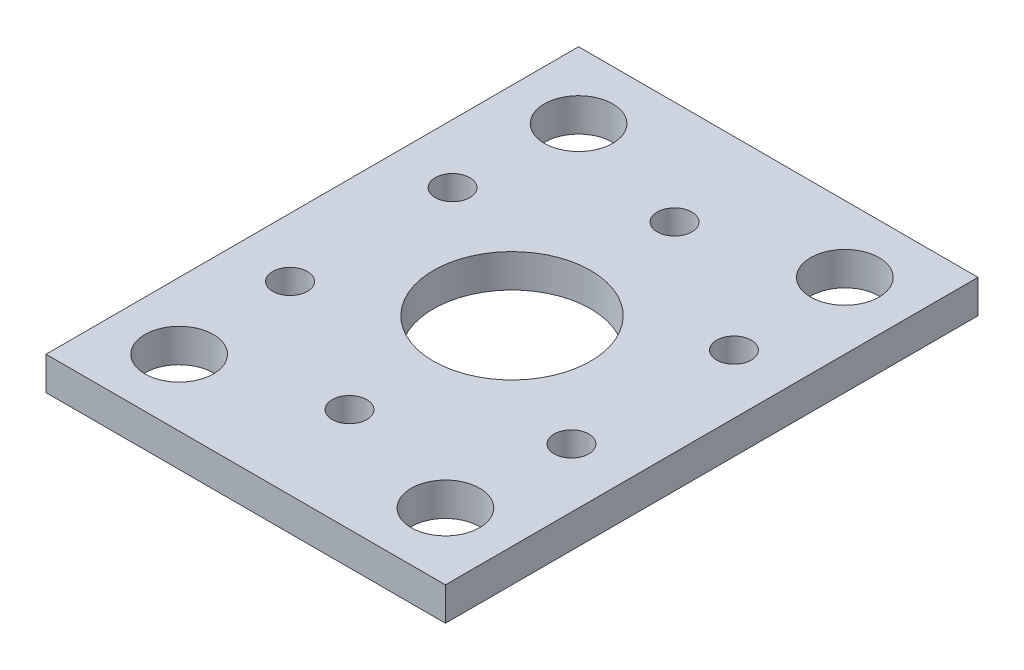
from build123d import *

# Parameters (mm, degrees)
SKETCH1_W          = 38.1
SKETCH1_H          = 50.8
SKETCH1_R          = 1.65
SKETCH1_R_2        = 7.5
SKETCH1_R_3        = 3.2639
BASE_EXTRUDE_DEPTH = 3.175


with BuildPart() as part:
    # Sketch1 → Base Extrude (new body)
    with BuildSketch(Plane(origin=(0, 0, 0), x_dir=(1, 0, 0), z_dir=(0, 1, 0))):
        with Locations((19.05, -25.4)):
            Rectangle(SKETCH1_W, SKETCH1_H)
        with Locations((19.05, -40.9)):
            Circle(SKETCH1_R, mode=Mode.SUBTRACT)
        with Locations((5.626606241, -33.15)):
            Circle(SKETCH1_R, mode=Mode.SUBTRACT)
        with Locations((5.626606241, -17.65)):
            Circle(SKETCH1_R, mode=Mode.SUBTRACT)
        with Locations((19.05, -9.9)):
            Circle(SKETCH1_R, mode=Mode.SUBTRACT)
        with Locations((32.473393759, -17.65)):
            Circle(SKETCH1_R, mode=Mode.SUBTRACT)
        with Locations((32.473393759, -33.15)):
            Circle(SKETCH1_R, mode=Mode.SUBTRACT)
        with Locations((19.05, -25.4)):
            Circle(SKETCH1_R_2, mode=Mode.SUBTRACT)
        with Locations((6.35, -6.35)):
            Circle(SKETCH1_R_3, mode=Mode.SUBTRACT)
        with Locations((31.75, -6.35)):
            Circle(SKETCH1_R_3, mode=Mode.SUBTRACT)
        with Locations((6.35, -44.45)):
            Circle(SKETCH1_R_3, mode=Mode.SUBTRACT)
        with Locations((31.75, -44.45)):
            Circle(SKETCH1_R_3, mode=Mode.SUBTRACT)
    extrude(amount=BASE_EXTRUDE_DEPTH)


solid = part.part
